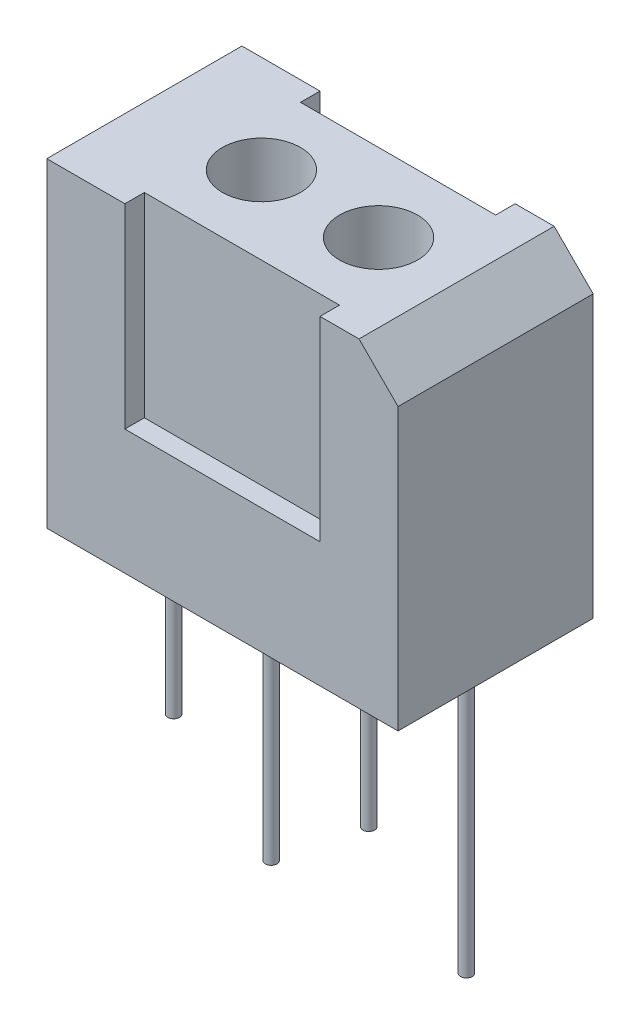
from build123d import *

# Parameters (mm, degrees)
SKETCH1_W           = 9
SKETCH1_H           = 8.2
BOSS_EXTRUDE1_DEPTH = 2.5
CHAMFER1_SIZE       = 1
SKETCH2_W           = 5
SKETCH2_H           = 0.5
CUT_EXTRUDE1_DEPTH  = 5
SKETCH3_R           = 1
CUT_EXTRUDE2_DEPTH  = 2
SKETCH4_R           = 0.15
BOSS_EXTRUDE2_DEPTH = 5
SKETCH5_R           = 0.15
BOSS_EXTRUDE3_DEPTH = 7


with BuildPart() as part:
    # Sketch1 → Boss-Extrude1 (new body, symmetric)
    with BuildSketch(Plane.XY):
        Rectangle(SKETCH1_W, SKETCH1_H)
    extrude(amount=BOSS_EXTRUDE1_DEPTH, both=True)

    # Chamfer1
    chamfer1_edges = [part.edges().sort_by_distance(p)[0] for p in [
        (4.5, 4.1, 0),
    ]]
    chamfer(chamfer1_edges, length=CHAMFER1_SIZE)

    # Sketch2 → Cut-Extrude1 (cut)
    with BuildSketch(Plane(origin=(0, 4.1, 0), x_dir=(1, 0, 0), z_dir=(0, 1, 0))):
        with Locations((0, -2.25)):
            Rectangle(SKETCH2_W, SKETCH2_H)
        with Locations((0, 2.25)):
            Rectangle(SKETCH2_W, SKETCH2_H)
    extrude(amount=-CUT_EXTRUDE1_DEPTH, mode=Mode.SUBTRACT)

    # Sketch3 → Cut-Extrude2 (cut)
    with BuildSketch(Plane(origin=(0, 4.1, 0), x_dir=(1, 0, 0), z_dir=(0, 1, 0))):
        with Locations((1.5, 0)):
            Circle(SKETCH3_R)
        with Locations((-1.5, 0)):
            Circle(SKETCH3_R)
    extrude(amount=-CUT_EXTRUDE2_DEPTH, mode=Mode.SUBTRACT)

    # Sketch4 → Boss-Extrude2 (add)
    with BuildSketch(Plane.XZ.offset(4.1)):
        with Locations((1.25, 0)):
            Circle(SKETCH4_R)
        with Locations((-3.75, 0)):
            Circle(SKETCH4_R)
    extrude(amount=BOSS_EXTRUDE2_DEPTH)

    # Sketch5 → Boss-Extrude3 (add)
    with BuildSketch(Plane.XZ.offset(4.1)):
        with Locations((-1.25, 0)):
            Circle(SKETCH5_R)
        with Locations((3.75, 0)):
            Circle(SKETCH5_R)
    extrude(amount=BOSS_EXTRUDE3_DEPTH)


solid = part.part
